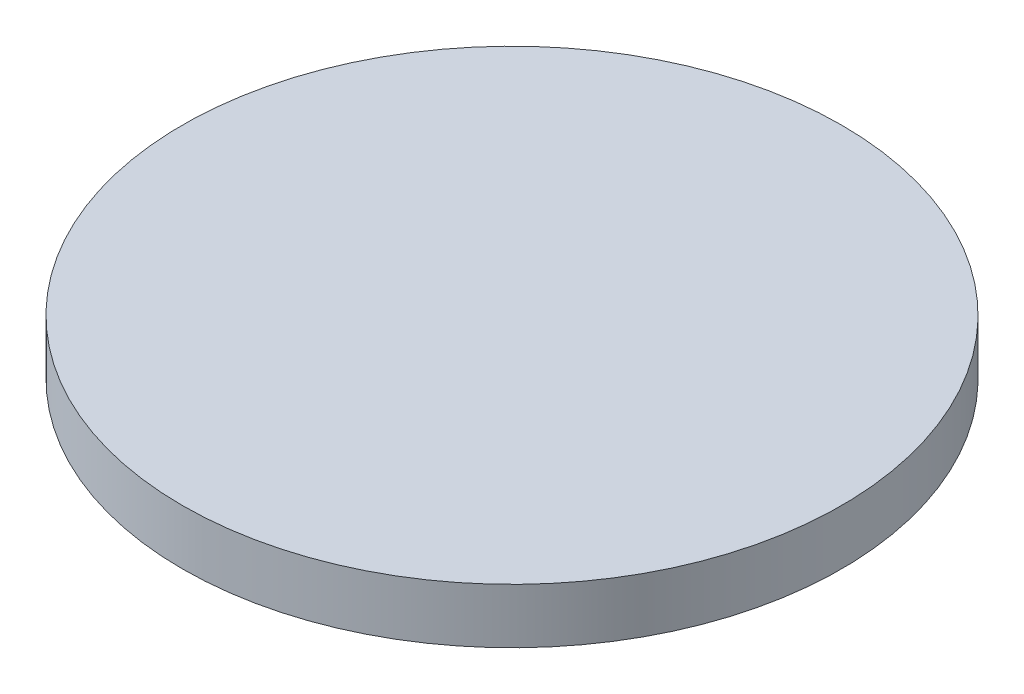
from build123d import *

# Parameters (mm, degrees)
SKETCH1_R           = 60
BOSS_EXTRUDE1_DEPTH = 10
SKETCH2_R           = 1.5
CUT_EXTRUDE1_DEPTH  = 4


with BuildPart() as part:
    # Sketch1 → Boss-Extrude1 (new body)
    with BuildSketch(Plane(origin=(0, 0, 0), x_dir=(1, 0, 0), z_dir=(0, 1, 0))):
        Circle(SKETCH1_R)
    extrude(amount=BOSS_EXTRUDE1_DEPTH)

    # Sketch2 → Cut-Extrude1 (cut)
    with BuildSketch(Plane.XZ):
        Circle(SKETCH2_R)
    extrude(amount=-CUT_EXTRUDE1_DEPTH, mode=Mode.SUBTRACT)


solid = part.part
